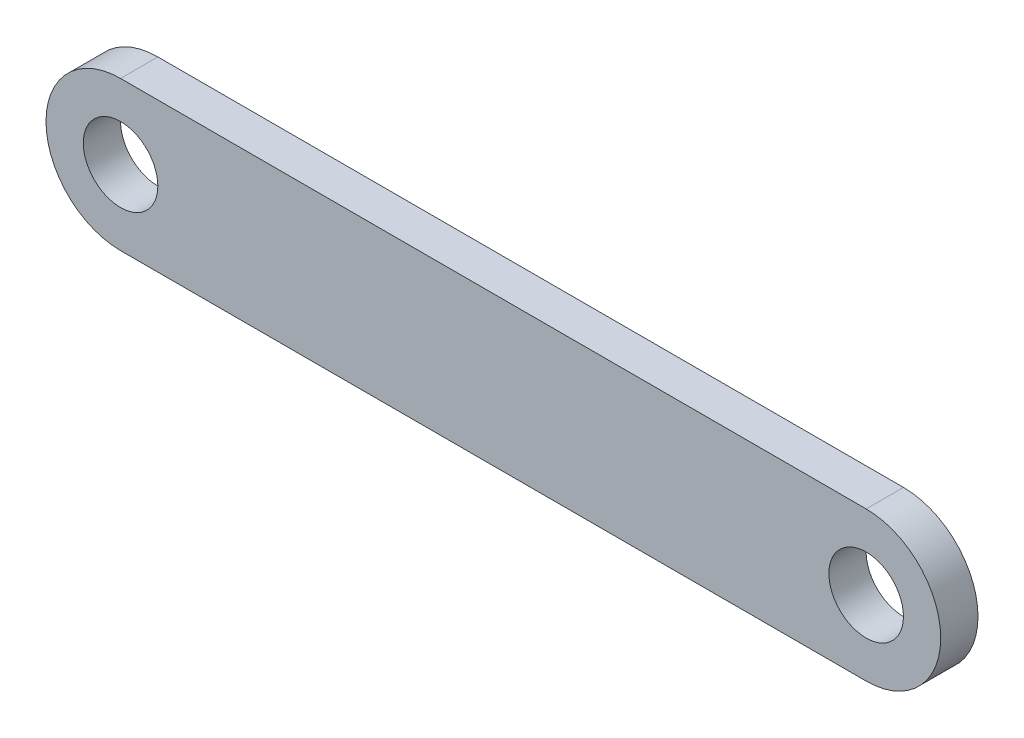
from build123d import *

# Parameters (mm, degrees)
SKETCH1_R           = 5
BOSS_EXTRUDE1_DEPTH = 5


with BuildPart() as part:
    # Sketch1 → Boss-Extrude1 (new body)
    with BuildSketch(Plane.XY):
        with BuildLine():
            Line((-50, 10), (50, 10))
            ThreePointArc((50, 10), (60, 0), (50, -10))
            Line((50, -10), (-50, -10))
            ThreePointArc((-50, -10), (-60, 0), (-50, 10))
        make_face()
        with Locations((-50, 0)):
            Circle(SKETCH1_R, mode=Mode.SUBTRACT)
        with Locations((50, 0)):
            Circle(SKETCH1_R, mode=Mode.SUBTRACT)
    extrude(amount=BOSS_EXTRUDE1_DEPTH)


solid = part.part
